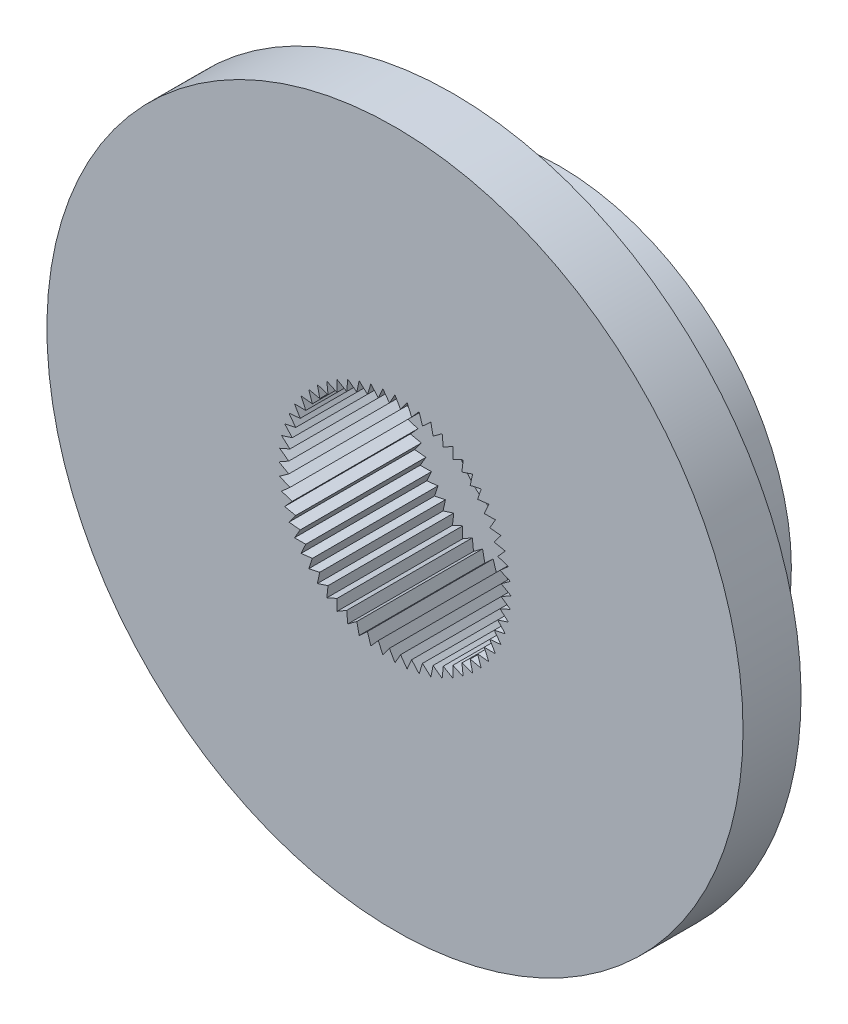
from build123d import *

# Parameters (mm, degrees)
BASE_EXTRUSION_DEPTH    = 2.75
ESQUISSE3_R             = 9
BOSS_EXTRU_1_DEPTH      = 1.5
ENL_V_MAT_EXTRU_2_DEPTH = 5.25
ESQUISSE5_R             = 4
BOSS_EXTRU_2_DEPTH      = 1
ESQUISSE6_R             = 2.5
BOSS_EXTRU_3_DEPTH      = 1.5
ESQUISSE7_R             = 1.75
ENL_V_MAT_EXTRU_3_DEPTH = 6.75


with BuildPart() as part:
    # Esquisse2 → Base-Extrusion (new body)
    with BuildSketch(Plane.XY):
        with BuildLine():
            Line((1.5, -5.809475019), (1.5, -8.874119675))
            ThreePointArc((1.5, -8.874119675), (0, -9), (-1.5, -8.874119675))
            Line((-1.5, -8.874119675), (-1.5, -5.809475019))
            ThreePointArc((-1.5, -5.809475019), (0, 6), (1.5, -5.809475019))
        make_face()
    extrude(amount=BASE_EXTRUSION_DEPTH)

    # Esquisse3 → Boss.-Extru.1 (add)
    with BuildSketch(Plane.XY.offset(2.75)):
        Circle(ESQUISSE3_R)
    extrude(amount=BOSS_EXTRU_1_DEPTH)

    # Esquisse1 → Enlèv. mat.-Extru.2 (cut, through all)
    with BuildSketch(Plane.XY):
        Polygon((0, 3), (-0.14392388, 2.746231221), (-0.31358539, 2.983565686), (-0.430194779, 2.716142937), (-0.623735072, 2.934442802), (-0.711752374, 2.656296022), (-0.927050983, 2.853169549), (-0.985511861, 2.567346173), (-1.220209929, 2.740636373), (-1.248473874, 2.450267942), (-1.5, 2.598076211), (-1.497757346, 2.306344062), (-1.763355757, 2.427050983), (-1.730631075, 2.137151394), (-2.007391819, 2.229434476), (-1.944543648, 1.944543648), (-2.229434476, 2.007391819), (-2.137151394, 1.730631075), (-2.427050983, 1.763355757), (-2.306344062, 1.497757346), (-2.598076211, 1.5), (-2.450267942, 1.248473874), (-2.740636373, 1.220209929), (-2.567346173, 0.985511861), (-2.853169549, 0.927050983), (-2.656296022, 0.711752374), (-2.934442802, 0.623735072), (-2.716142937, 0.430194779), (-2.983565686, 0.31358539), (-2.746231221, 0.14392388), (-3, 0), (-2.746231221, -0.14392388), (-2.983565686, -0.31358539), (-2.716142937, -0.430194779), (-2.934442802, -0.623735072), (-2.656296022, -0.711752374), (-2.853169549, -0.927050983), (-2.567346173, -0.985511861), (-2.740636373, -1.220209929), (-2.450267942, -1.248473874), (-2.598076211, -1.5), (-2.306344062, -1.497757346), (-2.427050983, -1.763355757), (-2.137151394, -1.730631075), (-2.229434476, -2.007391819), (-1.944543648, -1.944543648), (-2.007391819, -2.229434476), (-1.730631075, -2.137151394), (-1.763355757, -2.427050983), (-1.497757346, -2.306344062), (-1.5, -2.598076211), (-1.248473874, -2.450267942), (-1.220209929, -2.740636373), (-0.985511861, -2.567346173), (-0.927050983, -2.853169549), (-0.711752374, -2.656296022), (-0.623735072, -2.934442802), (-0.430194779, -2.716142937), (-0.31358539, -2.983565686), (-0.14392388, -2.746231221), (0, -3), (0.14392388, -2.746231221), (0.31358539, -2.983565686), (0.430194779, -2.716142937), (0.623735072, -2.934442802), (0.711752374, -2.656296022), (0.927050983, -2.853169549), (0.985511861, -2.567346173), (1.220209929, -2.740636373), (1.248473874, -2.450267942), (1.5, -2.598076211), (1.497757346, -2.306344062), (1.763355757, -2.427050983), (1.730631075, -2.137151394), (2.007391819, -2.229434476), (1.944543648, -1.944543648), (2.229434476, -2.007391819), (2.137151394, -1.730631075), (2.427050983, -1.763355757), (2.306344062, -1.497757346), (2.598076211, -1.5), (2.450267942, -1.248473874), (2.740636373, -1.220209929), (2.567346173, -0.985511861), (2.853169549, -0.927050983), (2.656296022, -0.711752374), (2.934442802, -0.623735072), (2.716142937, -0.430194779), (2.983565686, -0.31358539), (2.746231221, -0.14392388), (3, 0), (2.746231221, 0.14392388), (2.983565686, 0.31358539), (2.716142937, 0.430194779), (2.934442802, 0.623735072), (2.656296022, 0.711752374), (2.853169549, 0.927050983), (2.567346173, 0.985511861), (2.740636373, 1.220209929), (2.450267942, 1.248473874), (2.598076211, 1.5), (2.306344062, 1.497757346), (2.427050983, 1.763355757), (2.137151394, 1.730631075), (2.229434476, 2.007391819), (1.944543648, 1.944543648), (2.007391819, 2.229434476), (1.730631075, 2.137151394), (1.763355757, 2.427050983), (1.497757346, 2.306344062), (1.5, 2.598076211), (1.248473874, 2.450267942), (1.220209929, 2.740636373), (0.985511861, 2.567346173), (0.927050983, 2.853169549), (0.711752374, 2.656296022), (0.623735072, 2.934442802), (0.430194779, 2.716142937), (0.31358539, 2.983565686), (0.14392388, 2.746231221), align=None)
    extrude(amount=ENL_V_MAT_EXTRU_2_DEPTH, mode=Mode.SUBTRACT)

    # Esquisse5 → Boss.-Extru.2 (add)
    with BuildSketch(Plane(origin=(0, 0, 0), x_dir=(-1, 0, 0), z_dir=(0, 0, -1))):
        Circle(ESQUISSE5_R)
    extrude(amount=-BOSS_EXTRU_2_DEPTH)

    # Esquisse6 → Boss.-Extru.3 (add)
    with BuildSketch(Plane(origin=(0, 0, 0), x_dir=(-1, 0, 0), z_dir=(0, 0, -1))):
        Circle(ESQUISSE6_R)
    extrude(amount=BOSS_EXTRU_3_DEPTH)

    # Esquisse7 → Enlèv. mat.-Extru.3 (cut, through all)
    with BuildSketch(Plane(origin=(0, 0, -1.5), x_dir=(-1, 0, 0), z_dir=(0, 0, -1))):
        Circle(ESQUISSE7_R)
    extrude(amount=-ENL_V_MAT_EXTRU_3_DEPTH, mode=Mode.SUBTRACT)


solid = part.part
